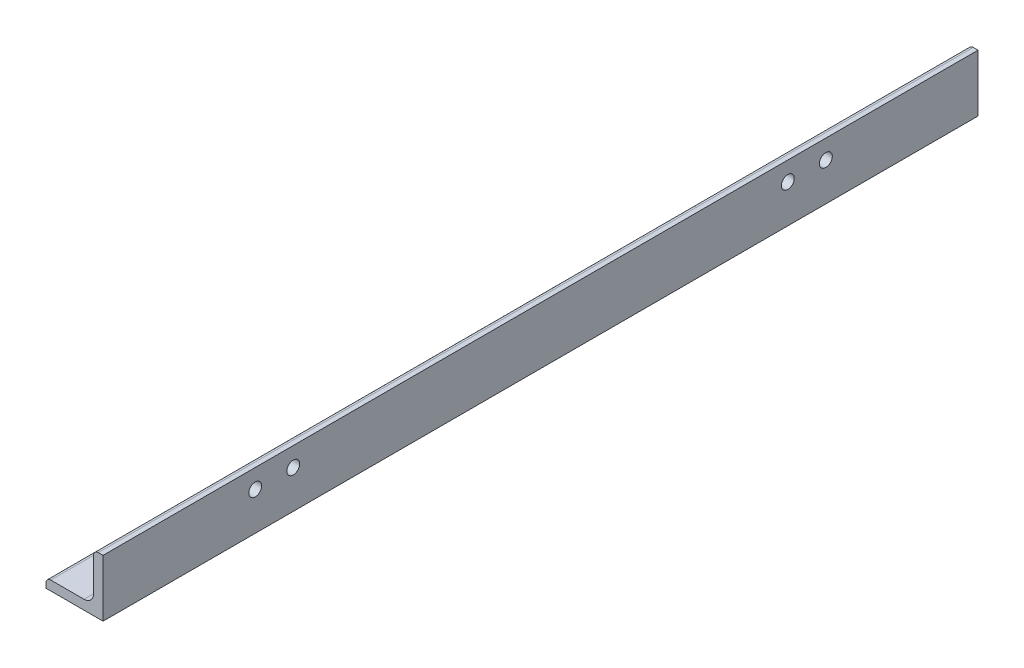
from build123d import *

# Parameters (mm, degrees)
BOSS_EXTRUDE1_DEPTH          = 146.05
F_18_0_1695_DIAMETER_HOLE1_D = 4.3053
MIRROR2_COPY_1_D             = 4.3053
SKETCH19_W                   = 2.15265
SKETCH19_H                   = 3.175


with BuildPart() as part:
    # Sketch2 → Boss-Extrude1 (new, symmetric)
    with BuildSketch(Plane.XY):
        with BuildLine():
            Line((-9.525, -9.525), (9.525, -9.525))
            Line((9.525, -9.525), (9.525, 9.525))
            Line((9.525, 9.525), (7.9375, 9.525))
            ThreePointArc((7.9375, 9.525), (6.814967985, 9.060032015), (6.35, 7.9375))
            Line((6.35, 7.9375), (6.35, -3.175))
            ThreePointArc((6.35, -3.175), (5.42006403, -5.42006403), (3.175, -6.35))
            Line((3.175, -6.35), (-7.9375, -6.35))
            ThreePointArc((-7.9375, -6.35), (-9.060032015, -6.814967985), (-9.525, -7.9375))
            Line((-9.525, -7.9375), (-9.525, -9.525))
        make_face()
    extrude(amount=BOSS_EXTRUDE1_DEPTH, both=True)

    # #18 (0.1695) Diameter Hole1 (through all)
    with Locations(Plane.ZY.offset(-6.35)):
        with Locations((-95.25, 3.175), (-82.55, 3.175)):
            f_18_0_1695_diameter_hole1 = Hole(F_18_0_1695_DIAMETER_HOLE1_D / 2)

    # Mirror1: #18 (0.1695) Diameter Hole1 across plane
    add(f_18_0_1695_diameter_hole1.mirror(Plane(origin=(0, 0, 0), x_dir=(0, 0, 1), z_dir=(0.7071067811865477, 0.7071067811865475, 0))), mode=Mode.SUBTRACT)

    # Mirror2: #18 (0.1695) Diameter Hole1 across plane
    add(f_18_0_1695_diameter_hole1.mirror(Plane.XY), mode=Mode.SUBTRACT)

    # Mirror2 copy 1 (through all)
    with Locations(Plane(origin=(0, -6.35, 0), x_dir=(0, 0, -1), z_dir=(0, 1, 0))):
        with Locations((-95.25, 3.175), (-82.55, 3.175)):
            Hole(MIRROR2_COPY_1_D / 2)

    # Sketch19 → #8 Clearance Hole1 (revolve, cut)
    with BuildSketch(Plane(origin=(1.5875, -6.35, -134.9375), x_dir=(0, 0, 1), z_dir=(1, 0, 0))):
        with Locations((1.076325, 1.5875)):
            Rectangle(SKETCH19_W, SKETCH19_H)
    revolve(axis=Axis((1.5875, 0, -134.9375), (0, -1, 0)), mode=Mode.SUBTRACT)


solid = part.part
